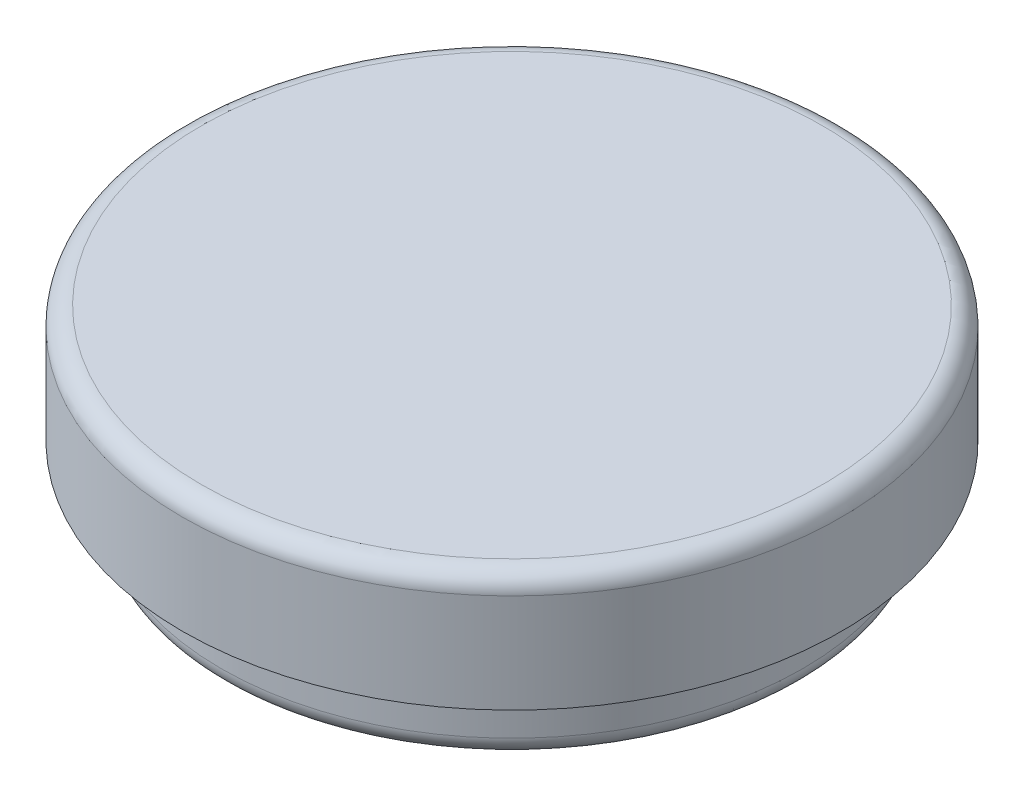
from build123d import *

# Parameters (mm, degrees)
SKETCH_1_R          = 14
EXTRUDE_1_DEPTH     = 5
SKETCH_2_R          = 12.35
EXTRUDE_2_DEPTH     = 3
SKETCH_3_R          = 11
CUT_EXTRUDE_1_DEPTH = 5
FILLET_2_R          = 0.8
FILLET_3_R          = 0.8


with BuildPart() as part:
    # Эскиз1 → Бобышка-Вытянуть1 (new body)
    with BuildSketch(Plane(origin=(0, 0, 0), x_dir=(1, 0, 0), z_dir=(0, 1, 0))):
        Circle(SKETCH_1_R)
    extrude(amount=EXTRUDE_1_DEPTH)

    # Эскиз2 → Бобышка-Вытянуть2 (add)
    with BuildSketch(Plane.XZ):
        Circle(SKETCH_2_R)
    extrude(amount=EXTRUDE_2_DEPTH)

    # Эскиз3 → Вырез-Вытянуть1 (cut)
    with BuildSketch(Plane.XZ.offset(3)):
        Circle(SKETCH_3_R)
    extrude(amount=-CUT_EXTRUDE_1_DEPTH, mode=Mode.SUBTRACT)

    # Скругление2
    fillet_2_edges = [part.edges().sort_by_distance(p)[0] for p in [
        (-12.35, -3, 0),
    ]]
    fillet(fillet_2_edges, radius=FILLET_2_R)

    # Скругление3
    fillet_3_edges = [part.edges().sort_by_distance(p)[0] for p in [
        (-14, 5, 0),
    ]]
    fillet(fillet_3_edges, radius=FILLET_3_R)


solid = part.part
